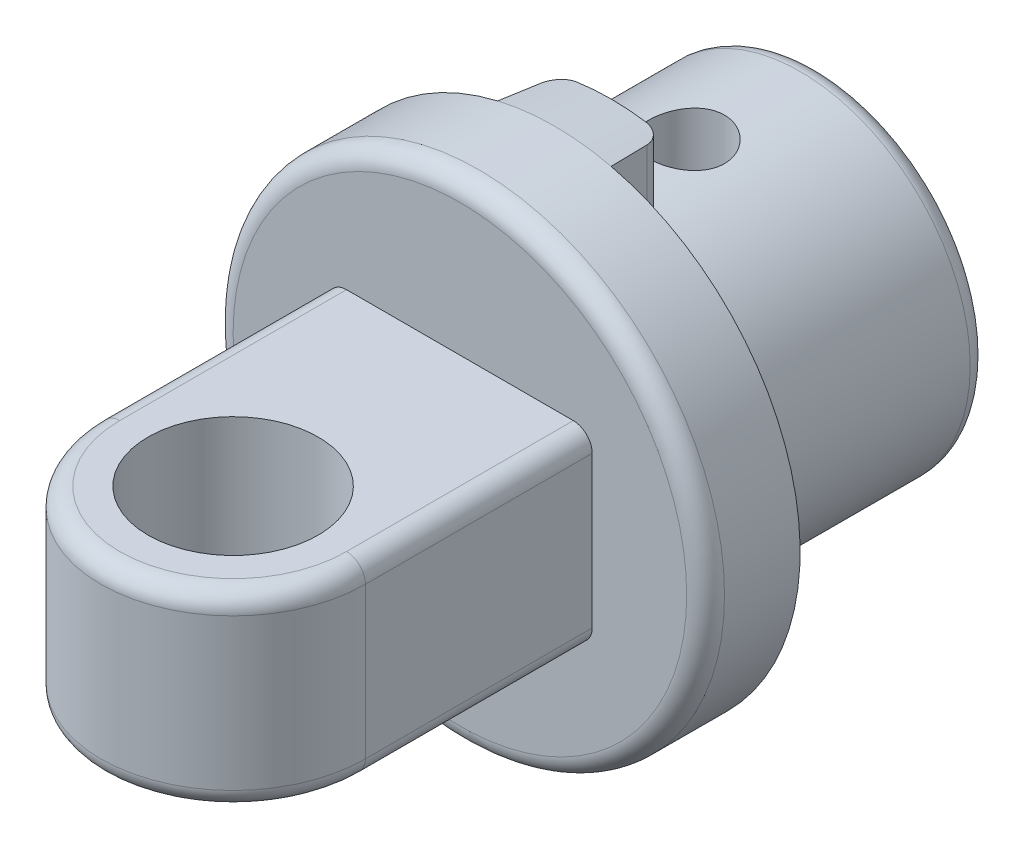
from build123d import *

# Parameters (mm, degrees)
ESQUISSE1_R             = 4.5
BASE_EXTRUSION_DEPTH    = 7
ESQUISSE2_R             = 6.5
BOSS_EXTRU_1_DEPTH      = 2.5
BOSS_EXTRU_2_DEPTH      = 2.5
ESQUISSE4_R             = 2.25
ESQUISSE4_R_2           = 1
ENL_V_MAT_EXTRU_1_DEPTH = 22.5
BOSS_EXTRU_3_DEPTH      = 1.5
BOSS_EXTRU_3_TAPER      = 5
CONG_1_R                = 0.5


with BuildPart() as part:
    # Esquisse1 → Base-Extrusion (new body)
    with BuildSketch(Plane.XY):
        Circle(ESQUISSE1_R)
    extrude(amount=BASE_EXTRUSION_DEPTH)

    # Esquisse2 → Boss.-Extru.1 (add)
    with BuildSketch(Plane.XY.offset(7)):
        Circle(ESQUISSE2_R)
    extrude(amount=BOSS_EXTRU_1_DEPTH)

    # Esquisse3 → Boss.-Extru.2 (add, symmetric)
    with BuildSketch(Plane(origin=(0, 0, 0), x_dir=(1, 0, 0), z_dir=(0, 1, 0))):
        with BuildLine():
            Line((-3.5, -9.5), (-3.5, -15.5))
            ThreePointArc((-3.5, -15.5), (0, -19), (3.5, -15.5))
            Line((3.5, -15.5), (3.5, -9.5))
            Line((3.5, -9.5), (-3.5, -9.5))
        make_face()
    extrude(amount=BOSS_EXTRU_2_DEPTH, both=True)

    # Esquisse4 → Enlèv. mat.-Extru.1 (cut, symmetric)
    with BuildSketch(Plane(origin=(0, 2.5, 0), x_dir=(-1, 0, 0), z_dir=(0, 1, 0))):
        with Locations((0, 15.5)):
            Circle(ESQUISSE4_R)
        with Locations((0, 3.5)):
            Circle(ESQUISSE4_R_2)
    extrude(amount=ENL_V_MAT_EXTRU_1_DEPTH, both=True, mode=Mode.SUBTRACT)

    # Esquisse5 → Boss.-Extru.3 (add)
    with BuildSketch(Plane(origin=(0, 0, 7), x_dir=(-1, 0, 0), z_dir=(0, 0, -1))):
        with BuildLine():
            ThreePointArc((1.5, 6.32455532), (0, 6.5), (-1.5, 6.32455532))
            Line((-1.5, 6.32455532), (-1.5, 4))
            Line((-1.5, 4), (1.5, 4))
            Line((1.5, 4), (1.5, 6.32455532))
        make_face()
    extrude(amount=BOSS_EXTRU_3_DEPTH, taper=BOSS_EXTRU_3_TAPER)

    # Congé1
    cong_1_edges = [part.edges().sort_by_distance(p)[0] for p in [
        (-6.5, 0, 9.5),
        (-1.368767005, 5.253360318, 5.5),
        (-4.5, 0, 0),
        (1.368767005, 5.253360318, 5.5),
        (-3.5, -2.5, 12.5),
        (-3.5, 2.5, 12.5),
        (0, -2.5, 19),
        (3.5, -2.5, 12.5),
        (3.5, 2.5, 12.5),
        (0, 2.5, 19),
    ]]
    fillet(cong_1_edges, radius=CONG_1_R)


solid = part.part
